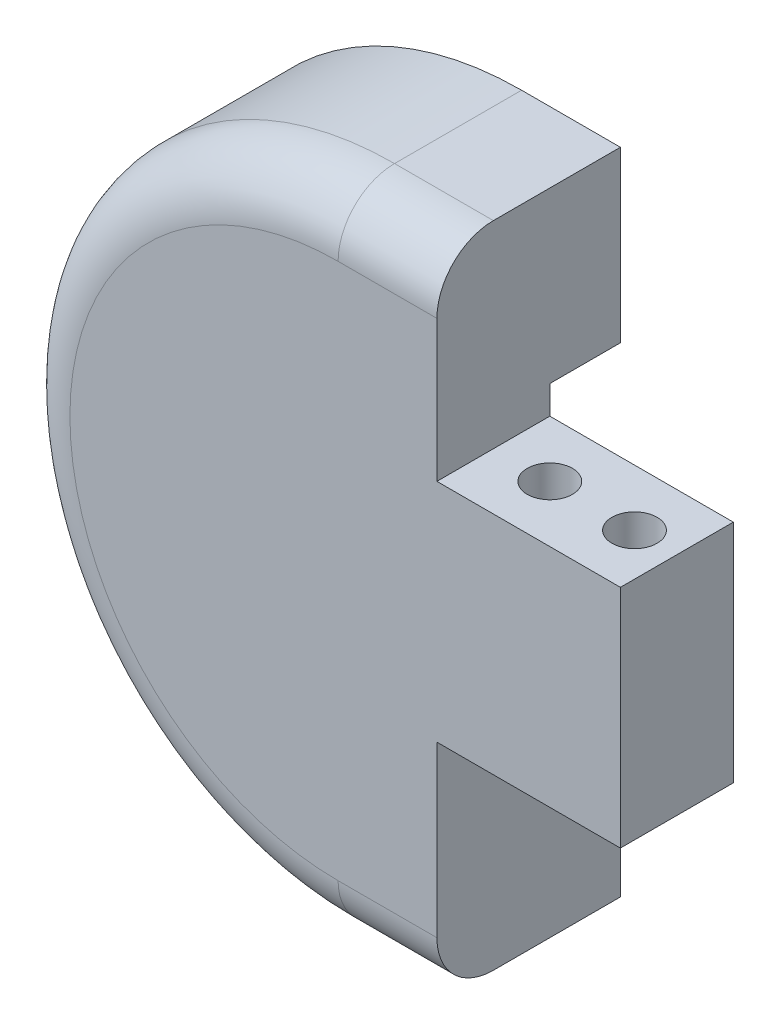
from build123d import *

# Parameters (mm, degrees)
BOSS_EXTRUDE1_DEPTH = 6.5
CUT_EXTRUDE1_START  = 11
SKETCH2_R           = 0.8
CUT_EXTRUDE1_DEPTH  = 23
FILLET1_R           = 2
POT_INSERT_DEPTH    = 2.5
POT_START           = 2.5
SKETCH6_R           = 2.75
POT_HOLE_DEPTH      = 1.5


with BuildPart() as part:
    # Sketch1 → Boss-Extrude1 (new body)
    with BuildSketch(Plane.XY):
        with BuildLine():
            Line((3.5, 12), (3.5, 5))
            Line((3.5, 5), (10, 5))
            Line((10, 5), (10, -3))
            Line((10, -3), (3.5, -3))
            Line((3.5, -3), (3.5, -11))
            Line((3.5, -11), (0, -11))
            ThreePointArc((0, -11), (-11.5, 0.5), (0, 12))
            Line((0, 12), (3.5, 12))
        make_face()
    extrude(amount=BOSS_EXTRUDE1_DEPTH)

    # Sketch2 → Cut-Extrude1 (cut, through all)
    with BuildSketch(Plane(origin=(0, 0, 0), x_dir=(1, 0, 0), z_dir=(0, 1, 0)).offset(CUT_EXTRUDE1_START)):
        with Locations((8.5, -4.5)):
            Circle(SKETCH2_R)
        with Locations((5.5, -4.5)):
            Circle(SKETCH2_R)
    extrude(amount=-CUT_EXTRUDE1_DEPTH, mode=Mode.SUBTRACT)

    # Fillet1
    fillet1_edges = [part.edges().sort_by_distance(p)[0] for p in [
        (1.75, 12, 6.5),
        (-11.5, 0.5, 6.5),
        (1.75, -11, 6.5),
    ]]
    fillet(fillet1_edges, radius=FILLET1_R)

    # Sketch5 → Pot Insert (cut)
    with BuildSketch(Plane.XY):
        Polygon((-5.5, -1), (-4, -4), (-4, -5), (0, -5), (4.25, -5), (4.25, -4), (10, -4), (10, 0.5), (10, 5), (4.25, 5), (4.25, 6), (0, 6), (-4, 6), (-4, 5), (-5.5, 2), (-5.5, 0.5), align=None)
    extrude(amount=POT_INSERT_DEPTH, mode=Mode.SUBTRACT)

    # Sketch6 → Pot Hole (cut)
    with BuildSketch(Plane.XY.offset(POT_START)):
        Circle(SKETCH6_R)
    extrude(amount=POT_HOLE_DEPTH, mode=Mode.SUBTRACT)


solid = part.part
